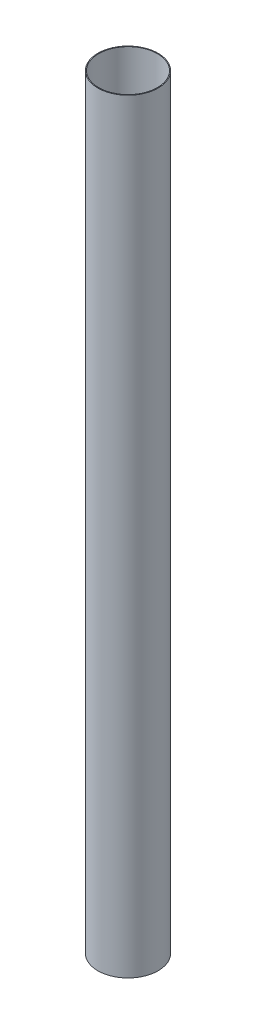
from build123d import *

# Parameters (mm, degrees)
SKETCH1_R           = 65.151
SKETCH1_R_2         = 63.5
BOSS_EXTRUDE1_DEPTH = 1651


with BuildPart() as part:
    # Sketch1 → Boss-Extrude1 (new body)
    with BuildSketch(Plane(origin=(0, 0, 0), x_dir=(1, 0, 0), z_dir=(0, 1, 0))):
        Circle(SKETCH1_R)
        Circle(SKETCH1_R_2, mode=Mode.SUBTRACT)
    extrude(amount=BOSS_EXTRUDE1_DEPTH)


solid = part.part
